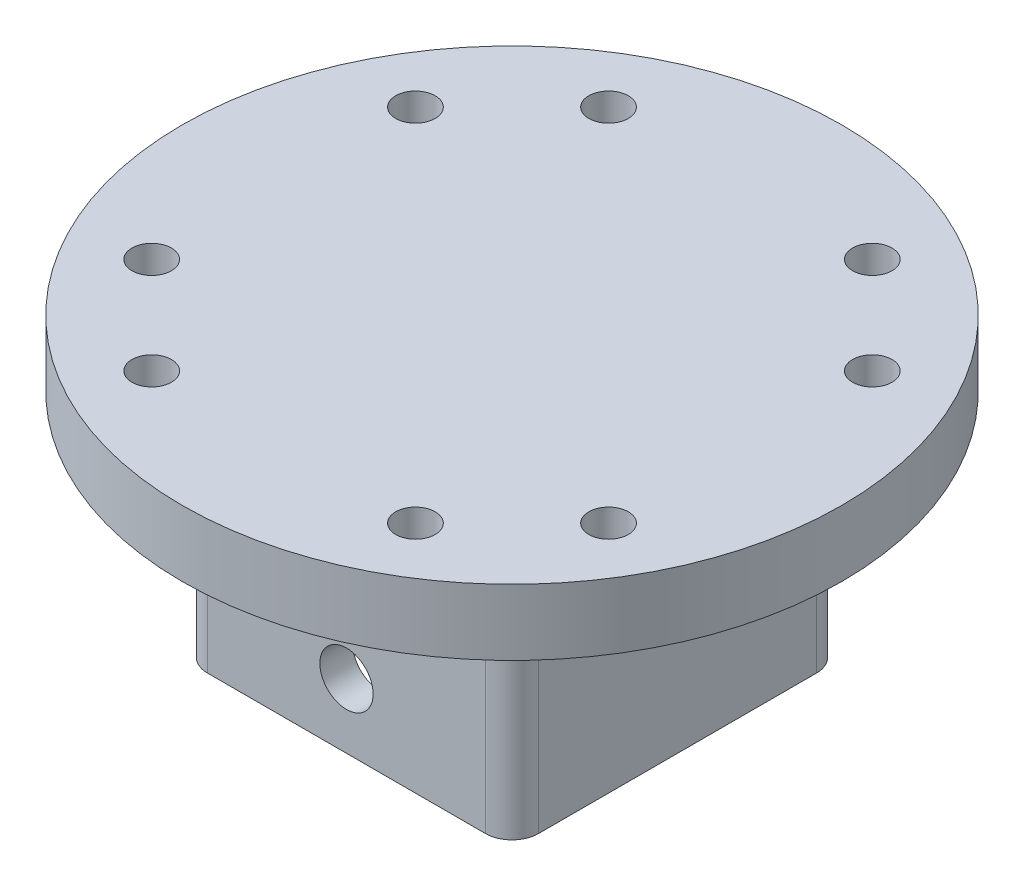
from build123d import *

# Parameters (mm, degrees)
SKETCH2_R               = 31.75
BOSS_EXTRUDE1_DEPTH     = 6.35
SKETCH3_W               = 31.877
SKETCH3_H               = 31.877
BOSS_EXTRUDE2_DEPTH     = 22.225
SKETCH4_W               = 25.527
SKETCH4_H               = 25.527
CUT_EXTRUDE1_DEPTH      = 23.225
SKETCH5_R               = 1.90000001
CUT_EXTRUDE2_DEPTH      = 7.35
SKETCH7_R               = 2.563499953
CUT_EXTRUDE3_DEPTH      = 32.75
CUT_EXTRUDE3_DEPTH_BACK = 32.75
CIRPATTERN2_COUNT       = 4
FILLET2_R               = 2.54
FILLET3_R               = 2.54


with BuildPart() as part:
    # Sketch2 → Boss-Extrude1 (new body)
    with BuildSketch(Plane(origin=(0, 0, 0), x_dir=(1, 0, 0), z_dir=(0, 1, 0))):
        Circle(SKETCH2_R)
    extrude(amount=BOSS_EXTRUDE1_DEPTH)

    # Sketch3 → Boss-Extrude2 (add)
    with BuildSketch(Plane(origin=(0, 0, 0), x_dir=(1, 0, 0), z_dir=(0, 1, 0))):
        Rectangle(SKETCH3_W, SKETCH3_H)
    extrude(amount=-BOSS_EXTRUDE2_DEPTH)

    # Sketch4 → Cut-Extrude1 (cut, through all)
    with BuildSketch(Plane(origin=(0, 0, 0), x_dir=(1, 0, 0), z_dir=(0, 1, 0))):
        Rectangle(SKETCH4_W, SKETCH4_H)
    extrude(amount=-CUT_EXTRUDE1_DEPTH, mode=Mode.SUBTRACT)

    # Sketch5 → Cut-Extrude2 (cut, through all)
    with BuildSketch(Plane(origin=(0, 0, 0), x_dir=(1, 0, 0), z_dir=(0, 1, 0))):
        with Locations((21.997045256, 12.7)):
            Circle(SKETCH5_R)
        with Locations((21.997045256, -12.7)):
            Circle(SKETCH5_R)
    cut_extrude2 = extrude(amount=CUT_EXTRUDE2_DEPTH, mode=Mode.SUBTRACT)

    # Sketch7 → Cut-Extrude3 (cut, two sides)
    with BuildSketch(Plane.XY) as cut_extrude3_sk:
        with Locations((0, -16.002)):
            Circle(SKETCH7_R)
    extrude(amount=CUT_EXTRUDE3_DEPTH, mode=Mode.SUBTRACT)
    extrude(cut_extrude3_sk.sketch, amount=-CUT_EXTRUDE3_DEPTH_BACK, mode=Mode.SUBTRACT)

    # CirPattern2: Cut-Extrude2 ×4 about axis
    cirpattern2_axis = Axis((0, 0, 0), (0, 1, 0))
    for i in range(1, CIRPATTERN2_COUNT):
        add(cut_extrude2.rotate(cirpattern2_axis, i * 360 / CIRPATTERN2_COUNT), mode=Mode.SUBTRACT)

    # Fillet2
    fillet2_edges = [part.edges().sort_by_distance(p)[0] for p in [
        (-15.9385, -11.1125, -15.9385),
        (15.9385, -11.1125, -15.9385),
        (15.9385, -11.1125, 15.9385),
        (-15.9385, -11.1125, 15.9385),
    ]]
    fillet(fillet2_edges, radius=FILLET2_R)

    # Fillet3
    fillet3_edges = [part.edges().sort_by_distance(p)[0] for p in [
        (-15.9385, 0, 0),
        (0, 0, 15.9385),
        (15.9385, 0, 0),
        (0, 0, -15.9385),
        (-15.194551224, 0, 15.194551224),
        (15.194551224, 0, 15.194551224),
        (15.194551224, 0, -15.194551224),
        (-15.194551224, 0, -15.194551224),
    ]]
    fillet(fillet3_edges, radius=FILLET3_R)


solid = part.part
